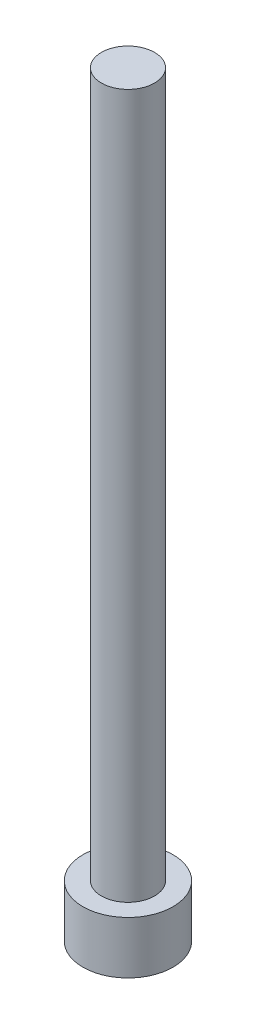
from build123d import *

# Parameters (mm, degrees)
SKETCH1_R           = 6.4
BOSS_EXTRUDE1_DEPTH = 7.45
SKETCH2_R           = 3.775
BOSS_EXTRUDE2_DEPTH = 100
CUT_EXTRUDE1_DEPTH  = 5
FILLET2_R           = 0.5
FILLET3_R           = 0.5


with BuildPart() as part:
    # Sketch1 → Boss-Extrude1 (new body)
    with BuildSketch(Plane(origin=(0, 0, 0), x_dir=(1, 0, 0), z_dir=(0, 1, 0))):
        Circle(SKETCH1_R)
    extrude(amount=BOSS_EXTRUDE1_DEPTH)

    # Sketch2 → Boss-Extrude2 (add)
    with BuildSketch(Plane(origin=(0, 7.45, 0), x_dir=(1, 0, 0), z_dir=(0, 1, 0))):
        Circle(SKETCH2_R)
    extrude(amount=BOSS_EXTRUDE2_DEPTH)

    # Sketch3 → Cut-Extrude1 (cut)
    with BuildSketch(Plane.XZ):
        Polygon((-3.608439182, 0), (-1.804219591, -3.125), (1.804219591, -3.125), (3.608439182, 0), (1.804219591, 3.125), (-1.804219591, 3.125), align=None)
    extrude(amount=-CUT_EXTRUDE1_DEPTH, mode=Mode.SUBTRACT)

    # Fillet2
    fillet2_edges = [part.edges().sort_by_distance(p)[0] for p in [
        (-2.706329387, 0, 1.5625),
        (-2.706329387, 0, -1.5625),
        (0, 0, -3.125),
        (2.706329387, 0, -1.5625),
        (2.706329387, 0, 1.5625),
        (0, 0, 3.125),
    ]]
    fillet(fillet2_edges, radius=FILLET2_R)

    # Fillet3
    fillet3_edges = [part.edges().sort_by_distance(p)[0] for p in [
        (-2.706329387, 5, 1.5625),
        (0, 5, 3.125),
        (2.706329387, 5, 1.5625),
        (2.706329387, 5, -1.5625),
        (0, 5, -3.125),
        (-2.706329387, 5, -1.5625),
    ]]
    fillet(fillet3_edges, radius=FILLET3_R)


solid = part.part
